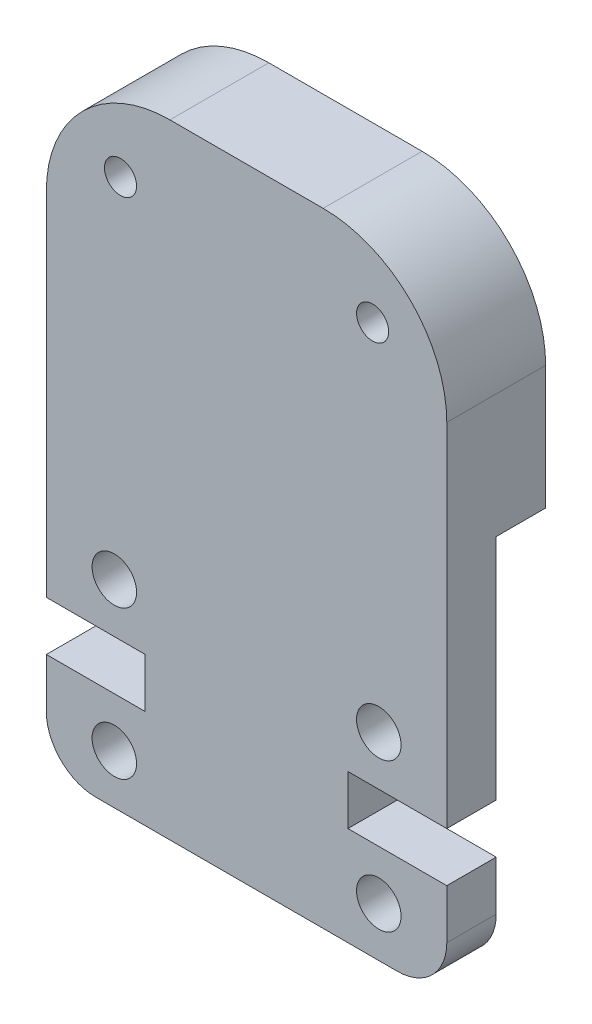
from build123d import *

# Parameters (mm, degrees)
SKETCH1_R           = 0.9
SKETCH1_R_2         = 0.65
BOSS_EXTRUDE1_DEPTH = 4
SKETCH2_W           = 16.2
SKETCH2_H           = 15.23
CUT_EXTRUDE1_DEPTH  = 2


with BuildPart() as part:
    # Sketch1 → Boss-Extrude1 (new body)
    with BuildSketch(Plane.XY):
        with BuildLine():
            Line((2, 0), (14.2, 0))
            ThreePointArc((14.2, 0), (15.614213562, 0.585786438), (16.2, 2))
            Line((16.2, 2), (16.2, 4))
            Line((16.2, 4), (12.2, 4))
            Line((12.2, 4), (12.2, 6))
            Line((12.2, 6), (16.2, 6))
            Line((16.2, 6), (16.2, 20.23))
            ThreePointArc((16.2, 20.23), (14.735533906, 23.765533906), (11.2, 25.23))
            Line((11.2, 25.23), (5, 25.23))
            ThreePointArc((5, 25.23), (1.464466094, 23.765533906), (0, 20.23))
            Line((0, 20.23), (0, 6))
            Line((0, 6), (4, 6))
            Line((4, 6), (4, 4))
            Line((4, 4), (0, 4))
            Line((0, 4), (0, 2))
            ThreePointArc((0, 2), (0.585786438, 0.585786438), (2, 0))
        make_face()
        with Locations((13.45, 2)):
            Circle(SKETCH1_R, mode=Mode.SUBTRACT)
        with Locations((13.2, 22.23)):
            Circle(SKETCH1_R_2, mode=Mode.SUBTRACT)
        with Locations((2.75, 8)):
            Circle(SKETCH1_R, mode=Mode.SUBTRACT)
        with Locations((13.45, 8)):
            Circle(SKETCH1_R, mode=Mode.SUBTRACT)
        with Locations((3, 22.23)):
            Circle(SKETCH1_R_2, mode=Mode.SUBTRACT)
        with Locations((2.75, 2)):
            Circle(SKETCH1_R, mode=Mode.SUBTRACT)
    extrude(amount=BOSS_EXTRUDE1_DEPTH)

    # Sketch2 → Cut-Extrude1 (cut)
    with BuildSketch(Plane.XY):
        with Locations((8.1, 7.615)):
            Rectangle(SKETCH2_W, SKETCH2_H)
    extrude(amount=CUT_EXTRUDE1_DEPTH, mode=Mode.SUBTRACT)


solid = part.part
